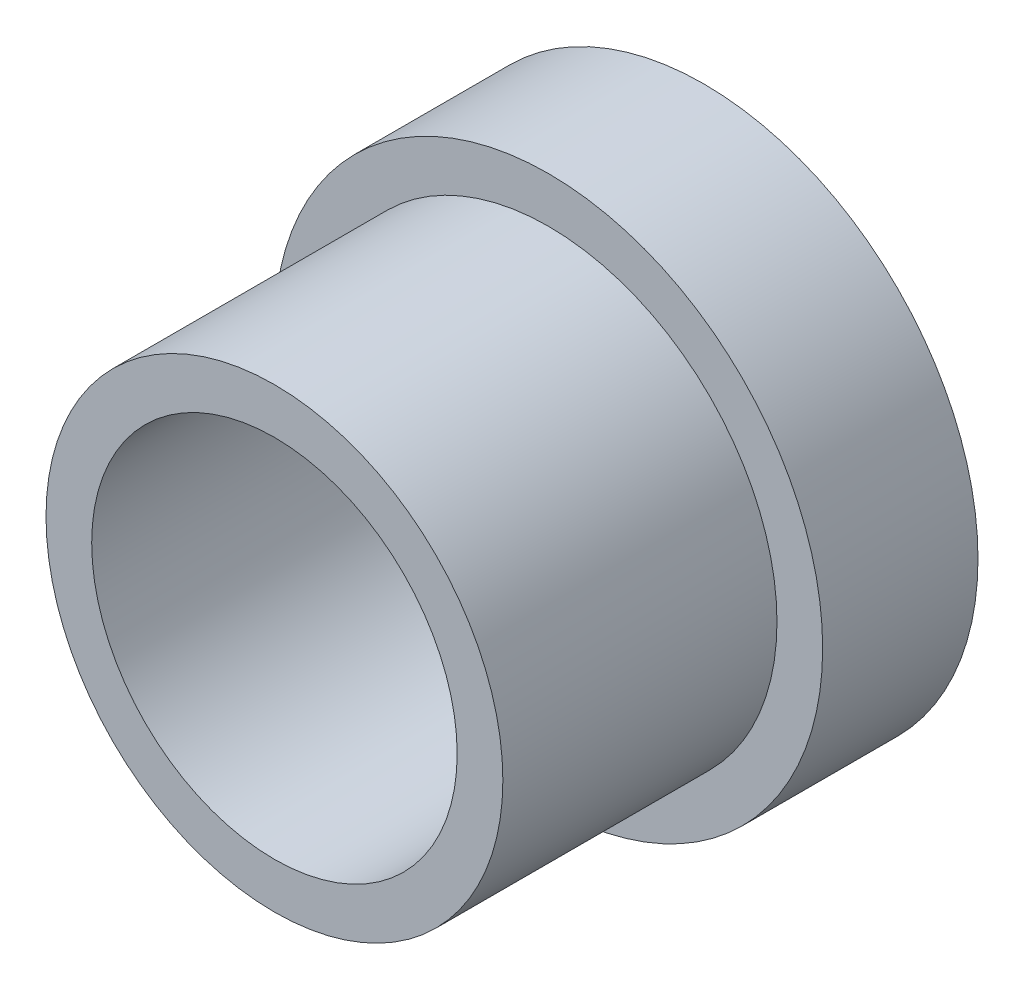
from build123d import *

# Parameters (mm, degrees)
SKETCH1_R           = 3
SKETCH1_R_2         = 2
BOSS_EXTRUDE1_DEPTH = 1.7
SKETCH3_R           = 2.5
SKETCH3_R_2         = 2
BOSS_EXTRUDE2_DEPTH = 3


with BuildPart() as part:
    # Sketch1 → Boss-Extrude1 (new body)
    with BuildSketch(Plane.XY):
        Circle(SKETCH1_R)
        Circle(SKETCH1_R_2, mode=Mode.SUBTRACT)
    extrude(amount=BOSS_EXTRUDE1_DEPTH)

    # Sketch3 → Boss-Extrude2 (add)
    with BuildSketch(Plane.XY.offset(1.7)):
        Circle(SKETCH3_R)
        Circle(SKETCH3_R_2, mode=Mode.SUBTRACT)
    extrude(amount=BOSS_EXTRUDE2_DEPTH)


solid = part.part
